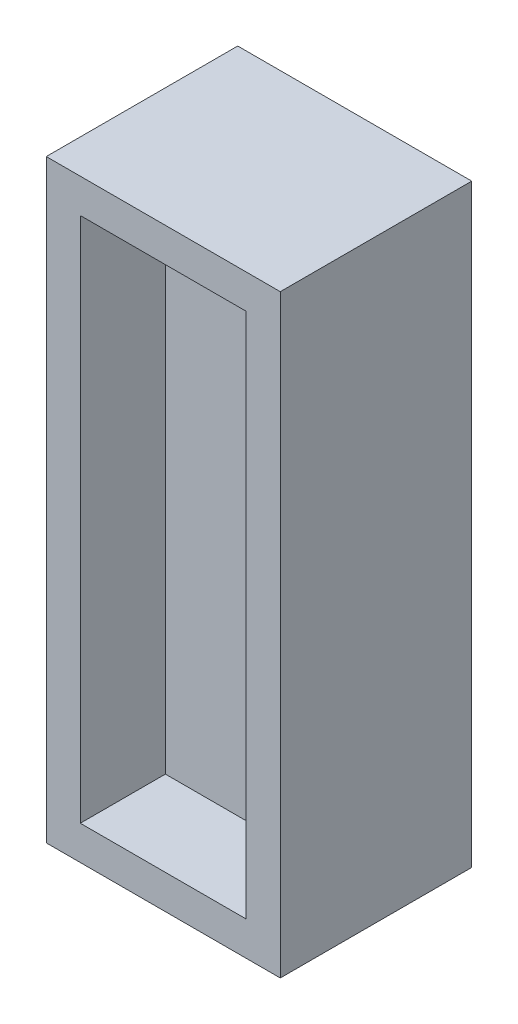
from build123d import *

# Parameters (mm, degrees)
SKETCH1_W           = 55
SKETCH1_H           = 139.7
BOSS_EXTRUDE1_DEPTH = 45
SKETCH2_W           = 39
SKETCH2_H           = 123.7
CUT_EXTRUDE1_DEPTH  = 20


with BuildPart() as part:
    # Sketch1 → Boss-Extrude1 (new body)
    with BuildSketch(Plane.XY):
        Rectangle(SKETCH1_W, SKETCH1_H)
    extrude(amount=BOSS_EXTRUDE1_DEPTH)

    # Sketch2 → Cut-Extrude1 (cut)
    with BuildSketch(Plane.XY.offset(45)):
        Rectangle(SKETCH2_W, SKETCH2_H)
    extrude(amount=-CUT_EXTRUDE1_DEPTH, mode=Mode.SUBTRACT)


solid = part.part
